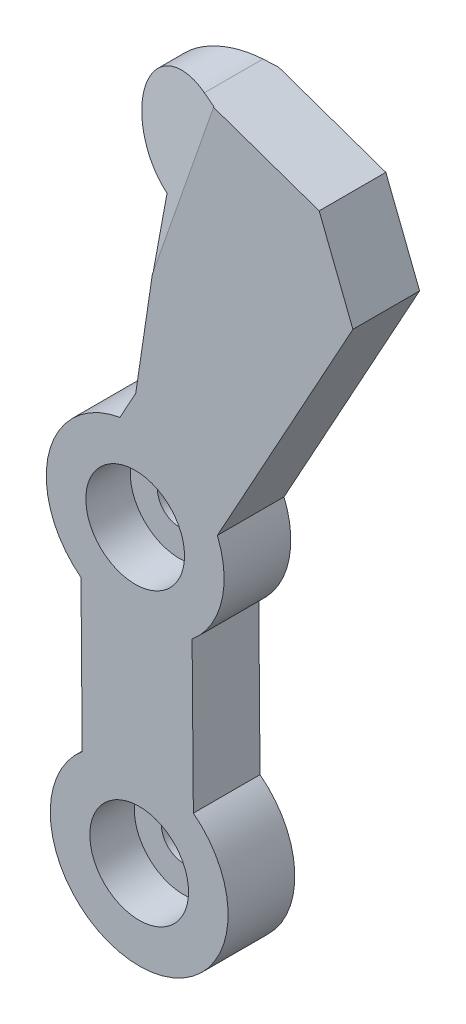
from build123d import *

# Parameters (mm, degrees)
BOSS_EXTRUDE1_DEPTH     = 15
SKETCH2_R               = 11.1
CUT_EXTRUDE1_DEPTH      = 10
SKETCH3_R               = 5
CUT_EXTRUDE2_DEPTH      = 10
CUT_EXTRUDE_THIN3_DEPTH = 63


with BuildPart() as part:
    # Sketch1 → Boss-Extrude1 (new body)
    with BuildSketch(Plane.XY):
        with BuildLine():
            Line((5.505816945, 85.326012217), (5.307768654, 85.393580353))
            ThreePointArc((5.307768654, 85.393580353), (-2.005055015, 101.475976607), (13.940536847, 109.082484312))
            Line((13.940536847, 109.082484312), (40.538740524, 99.7887516))
            Line((40.538740524, 99.7887516), (48.129208704, 80.495248668))
            Line((48.129208704, 80.495248668), (17.636215156, 25.115965593))
            ThreePointArc((17.636215156, 25.115965593), (18.579608232, 12.6739017), (11.964278199, 2.09409296))
            Line((11.964278199, 2.09409296), (12.243619866, -31.678974911))
            ThreePointArc((12.243619866, -31.678974911), (0.468324559, -67.537617109), (-12.751239862, -32.185913949))
            Line((-12.751239862, -32.185913949), (-13.03091257, 1.603476045))
            ThreePointArc((-13.03091257, 1.603476045), (-20.259022529, 22.242640416), (-4.270337109, 37.161843413))
            Line((-4.270337109, 37.161843413), (-0.71558036, 43.617748767))
            Line((-0.71558036, 43.617748767), (5.505816945, 85.326012217))
        make_face()
    extrude(amount=BOSS_EXTRUDE1_DEPTH)

    # Sketch2 → Cut-Extrude1 (cut)
    with BuildSketch(Plane.XY.offset(15)):
        with Locations((-0.839707244, 17.458270673)):
            Circle(SKETCH2_R)
        with Locations((0.062773329, -47.541729327)):
            Circle(SKETCH2_R)
    extrude(amount=-CUT_EXTRUDE1_DEPTH, mode=Mode.SUBTRACT)

    # Sketch3 → Cut-Extrude2 (cut)
    with BuildSketch(Plane.XY.offset(5)):
        with Locations((-0.839707244, 17.458270673)):
            Circle(SKETCH3_R)
        with Locations((0.062773329, -47.541729327)):
            Circle(SKETCH3_R)
    extrude(amount=-CUT_EXTRUDE2_DEPTH, mode=Mode.SUBTRACT)

    # Sketch6 → Cut-Extrude-Thin3 (cut)
    with BuildSketch(Plane(origin=(35.484462303, 101.554777284, 0), x_dir=(0.944031293, -0.329855904, 0), z_dir=(0.329855904, 0.944031293, 0))):
        Polygon((-20.418832703, -0.085187968), (-37.64557492, -6.976961591), (-41.359981954, 2.307605194), (-24.133239737, 9.199378817), align=None)
        Polygon((-37.640333131, -10.87506916), (-19.777391753, -14.888150458), (-21.969352424, -24.644958769), (-39.832293801, -20.631877471), align=None)
    extrude(amount=-CUT_EXTRUDE_THIN3_DEPTH, mode=Mode.SUBTRACT)


solid = part.part
